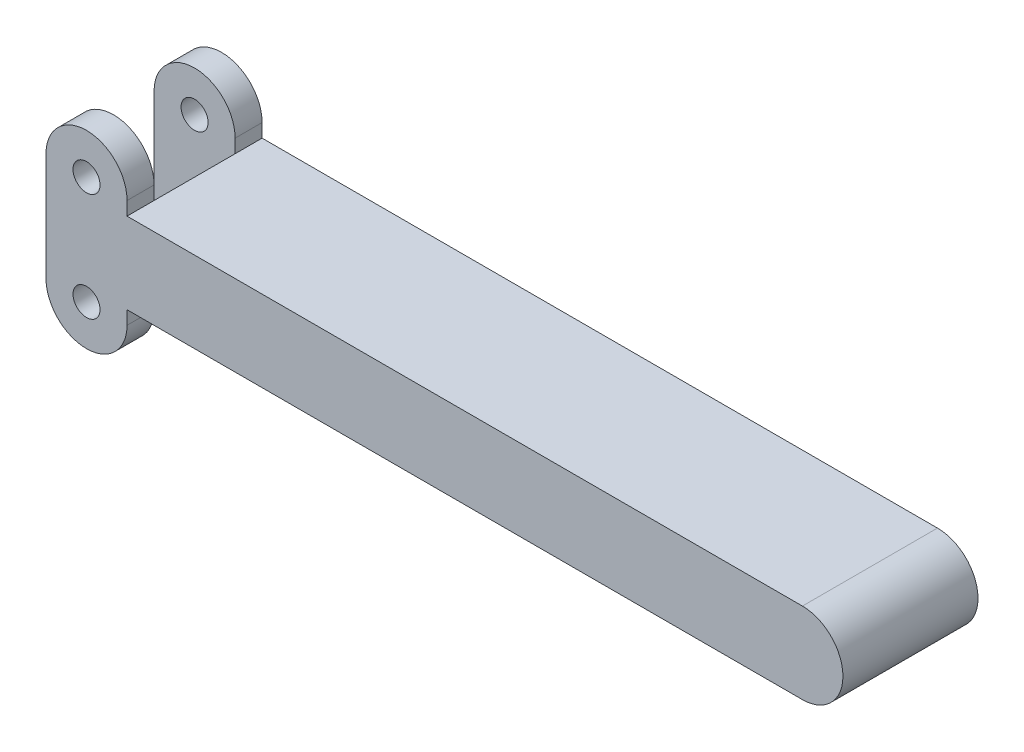
from build123d import *

# Parameters (mm, degrees)
SKETCH1_R           = 3.175
BOSS_EXTRUDE1_DEPTH = 31.75
SKETCH2_W           = 19.05
SKETCH2_H           = 25.4
SKETCH2_H_2         = 9.525
CUT_EXTRUDE1_DEPTH  = 19.05


with BuildPart() as part:
    # Sketch1 → Boss-Extrude1 (new body)
    with BuildSketch(Plane.XY):
        with BuildLine():
            Line((-9.525, 25.4), (-9.525, 0))
            ThreePointArc((-9.525, 0), (0, -9.525), (9.525, 0))
            Line((9.525, 0), (9.525, 3.175))
            Line((9.525, 3.175), (168.275, 3.175))
            ThreePointArc((168.275, 3.175), (177.8, 12.7), (168.275, 22.225))
            Line((168.275, 22.225), (9.525, 22.225))
            Line((9.525, 22.225), (9.525, 25.4))
            ThreePointArc((9.525, 25.4), (0, 34.925), (-9.525, 25.4))
        make_face()
        Circle(SKETCH1_R, mode=Mode.SUBTRACT)
        with Locations((0, 25.4)):
            Circle(SKETCH1_R, mode=Mode.SUBTRACT)
    extrude(amount=BOSS_EXTRUDE1_DEPTH)

    # Sketch2 → Cut-Extrude1 (cut)
    with BuildSketch(Plane.ZY.offset(9.525)):
        with Locations((15.875, 12.7)):
            Rectangle(SKETCH2_W, SKETCH2_H)
        with Locations((15.875, 30.1625)):
            Rectangle(SKETCH2_W, SKETCH2_H_2)
        with Locations((15.875, -4.7625)):
            Rectangle(SKETCH2_W, SKETCH2_H_2)
    extrude(amount=-CUT_EXTRUDE1_DEPTH, mode=Mode.SUBTRACT)


solid = part.part
